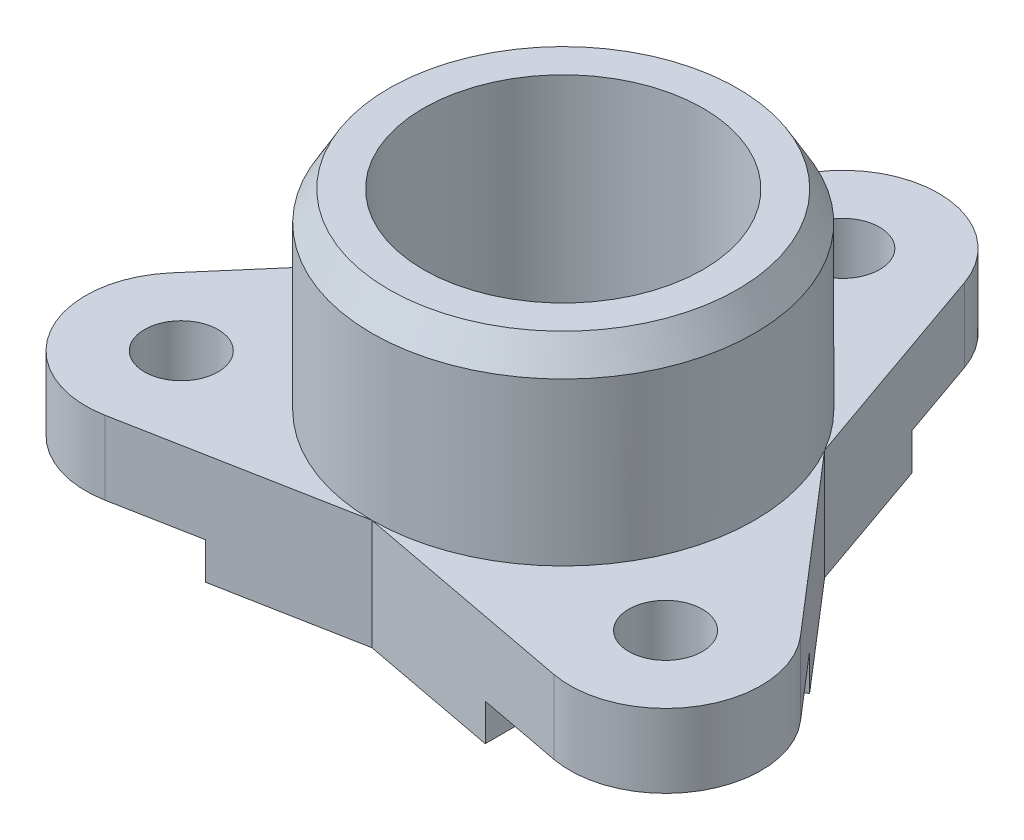
from build123d import *

# Parameters (mm, degrees)
SKETCH1_R           = 1.25
SKETCH1_R_2         = 4.75
BOSS_EXTRUDE1_DEPTH = 2.5
SKETCH1_9_R         = 6.5
SKETCH1_9_R_2       = 4.75
BOSS_EXTRUDE2_DEPTH = 9
CHAMFER1_SIZE       = 1
CHAMFER1_SIZE2      = 0.577350269
BOSS_EXTRUDE3_DEPTH = 1.25
CIRPATTERN1_COUNT   = 3


with BuildPart() as part:
    # Sketch1 → Boss-Extrude1 (new body)
    with BuildSketch(Plane(origin=(0, 0, 0), x_dir=(1, 0, 0), z_dir=(0, 1, 0))):
        with BuildLine():
            ThreePointArc((3.067754869, 10.573023795), (0, 12.75), (-3.067754869, 10.573023795))
            Line((-3.067754869, 10.573023795), (-5.629165125, 3.25))
            Line((-5.629165125, 3.25), (-10.690384636, -2.629758248))
            ThreePointArc((-10.690384636, -2.629758248), (-11.041823898, -6.375), (-7.622629767, -7.943265547))
            Line((-7.622629767, -7.943265547), (0, -6.5))
            Line((0, -6.5), (7.622629767, -7.943265547))
            ThreePointArc((7.622629767, -7.943265547), (11.041823898, -6.375), (10.690384636, -2.629758248))
            Line((10.690384636, -2.629758248), (5.629165125, 3.25))
            Line((5.629165125, 3.25), (3.067754869, 10.573023795))
        make_face()
        with Locations((0, 9.5)):
            Circle(SKETCH1_R, mode=Mode.SUBTRACT)
        Circle(SKETCH1_R_2, mode=Mode.SUBTRACT)
        with Locations((-8.227241336, -4.75)):
            Circle(SKETCH1_R, mode=Mode.SUBTRACT)
        with Locations((8.227241336, -4.75)):
            Circle(SKETCH1_R, mode=Mode.SUBTRACT)
    extrude(amount=BOSS_EXTRUDE1_DEPTH)

    # Sketch1_9 → Boss-Extrude2 (add)
    with BuildSketch(Plane(origin=(0, 0, 0), x_dir=(1, 0, 0), z_dir=(0, 1, 0))):
        Circle(SKETCH1_9_R)
        Circle(SKETCH1_9_R_2, mode=Mode.SUBTRACT)
    extrude(amount=BOSS_EXTRUDE2_DEPTH)

    # Chamfer1
    chamfer1_edges = [part.edges().sort_by_distance(p)[0] for p in [
        (-6.5, 9, 0),
    ]]
    chamfer1_side = [part.faces().sort_by_distance(p)[0] for p in [
        (-6.5, 5.75, 0),
    ]]
    chamfer(chamfer1_edges, length=CHAMFER1_SIZE, length2=CHAMFER1_SIZE2, reference=chamfer1_side[0])

    # Sketch1_10 → Boss-Extrude3 (add)
    with BuildSketch(Plane(origin=(0, 0, 0), x_dir=(1, 0, 0), z_dir=(0, 1, 0))):
        Polygon((-4.75, -7.399363022), (0, -6.5), (4.75, -7.399363022), (4.75, -5.75), (-4.75, -5.75), align=None)
    boss_extrude3 = extrude(amount=-BOSS_EXTRUDE3_DEPTH)

    # CirPattern1: Boss-Extrude3 ×3 about axis
    cirpattern1_axis = Axis((0, 2.5, 0), (0, -1, 0))
    for i in range(1, CIRPATTERN1_COUNT):
        add(boss_extrude3.rotate(cirpattern1_axis, i * 360 / CIRPATTERN1_COUNT))


solid = part.part
